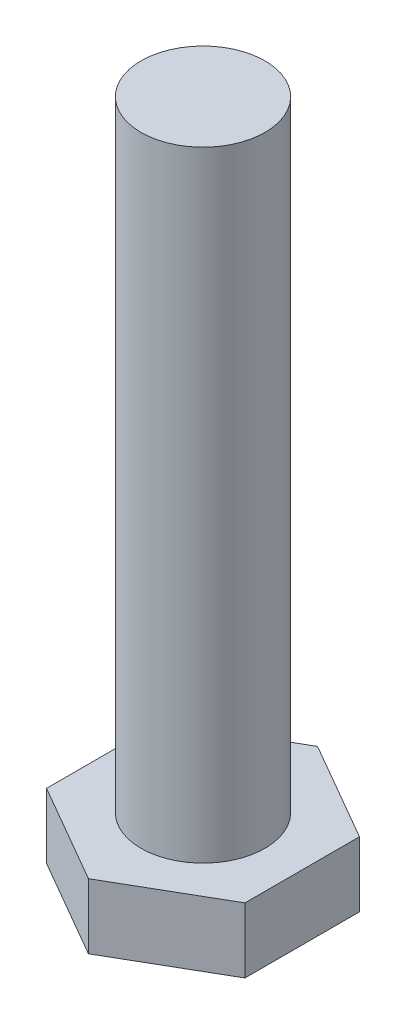
from build123d import *

# Parameters (mm, degrees)
EXTRUDE_1_DEPTH = 3.2
SKETCH_2_R      = 2.5
EXTRUDE_2_DEPTH = 25
CHAMFER_1_SIZE  = 1
CHAMFER_1_SIZE2 = 0.577350269


with BuildPart() as part:
    # Эскиз1 → Бобышка-Вытянуть1 (new body)
    with BuildSketch(Plane(origin=(0, 0, 0), x_dir=(1, 0, 0), z_dir=(0, 1, 0))):
        Polygon((4, -2.309401077), (4, 2.309401077), (0, 4.618802154), (-4, 2.309401077), (-4, -2.309401077), (0, -4.618802154), align=None)
    extrude(amount=EXTRUDE_1_DEPTH)

    # Эскиз2 → Бобышка-Вытянуть2 (add)
    with BuildSketch(Plane(origin=(0, 3.2, 0), x_dir=(1, 0, 0), z_dir=(0, 1, 0))):
        Circle(SKETCH_2_R)
    extrude(amount=EXTRUDE_2_DEPTH)

    # Фаска1
    chamfer_1_edges = [part.edges().sort_by_distance(p)[0] for p in [
        (-2, 0, 3.464101615),
        (-4, 0, 0),
        (-2, 0, -3.464101615),
        (2, 0, -3.464101615),
        (4, 0, 0),
        (2, 0, 3.464101615),
    ]]
    chamfer_1_side = [part.faces().sort_by_distance(p)[0] for p in [
        (0, 0, 0),
    ]]
    chamfer(chamfer_1_edges, length=CHAMFER_1_SIZE, length2=CHAMFER_1_SIZE2, reference=chamfer_1_side[0])


solid = part.part
